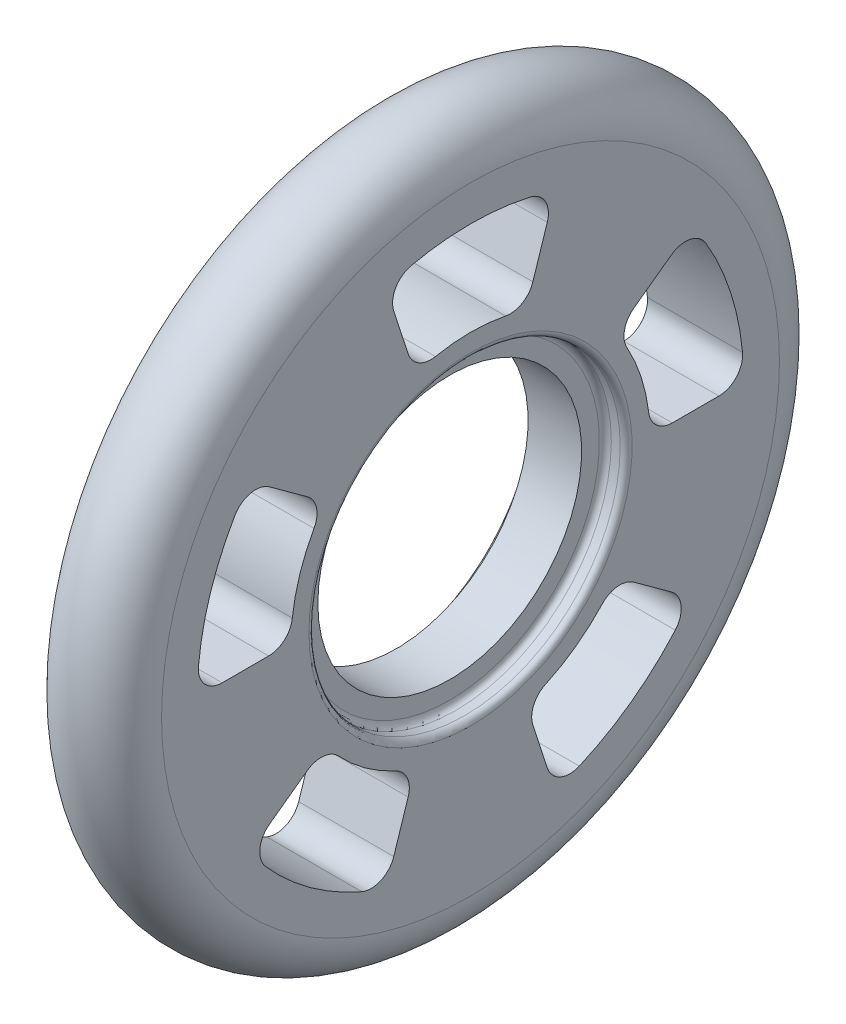
from build123d import *

# Parameters (mm, degrees)
CUT_EXTRUDE1_DEPTH = 8
CIRPATTERN1_COUNT  = 5


with BuildPart() as part:
    # Sketch3 → Revolve1 (revolve)
    with BuildSketch(Plane.XY):
        with BuildLine():
            Line((-2.25, 11.1), (2.25, 11.1))
            Line((2.25, 11.1), (2.25, 12.6))
            ThreePointArc((2.25, 12.6), (2.396446609, 12.953553391), (2.75, 13.1))
            Line((2.75, 13.1), (3.5, 13.1))
            ThreePointArc((3.5, 13.1), (3.853553391, 13.246446609), (4, 13.6))
            Line((4, 13.6), (4, 26))
            ThreePointArc((4, 26), (0, 30), (-4, 26))
            Line((-4, 26), (-4, 13.6))
            ThreePointArc((-4, 13.6), (-3.853553391, 13.246446609), (-3.5, 13.1))
            Line((-3.5, 13.1), (-2.75, 13.1))
            ThreePointArc((-2.75, 13.1), (-2.396446609, 12.953553391), (-2.25, 12.6))
            Line((-2.25, 12.6), (-2.25, 11.1))
        make_face()
    revolve(axis=Axis((0, 0, 0), (1, 0, 0)))

    # Sketch6 → Cut-Extrude1 (cut)
    with BuildSketch(Plane(origin=(4, 0, 0), x_dir=(0, 0, -1), z_dir=(1, 0, 0))):
        with BuildLine():
            Line((13.739242908, 9.982144275), (16.912132133, 12.287383234))
            ThreePointArc((16.912132133, 12.287383234), (18.494388462, 12.627564412), (19.810340984, 11.685477744))
            ThreePointArc((19.810340984, 11.685477744), (21.874299875, 7.107390871), (22.895454004, 2.19047619))
            ThreePointArc((22.895454004, 2.19047619), (22.3845707, 0.654814582), (20.90454496, 0))
            Line((20.90454496, 0), (16.982638193, 0))
            ThreePointArc((16.982638193, 0), (15.653698062, 0.505370237), (14.99636472, 1.766081871))
            ThreePointArc((14.99636472, 1.766081871), (14.360953396, 4.666156615), (13.170390791, 7.385851773))
            ThreePointArc((13.170390791, 7.385851773), (12.961156929, 8.792159755), (13.739242908, 9.982144275))
        make_face()
    cut_extrude1 = extrude(amount=-CUT_EXTRUDE1_DEPTH, mode=Mode.SUBTRACT)

    # CirPattern1: Cut-Extrude1 ×5 about axis
    cirpattern1_axis = Axis((0, 0, 0), (1, 0, 0))
    for i in range(1, CIRPATTERN1_COUNT):
        add(cut_extrude1.rotate(cirpattern1_axis, i * 360 / CIRPATTERN1_COUNT), mode=Mode.SUBTRACT)


solid = part.part
